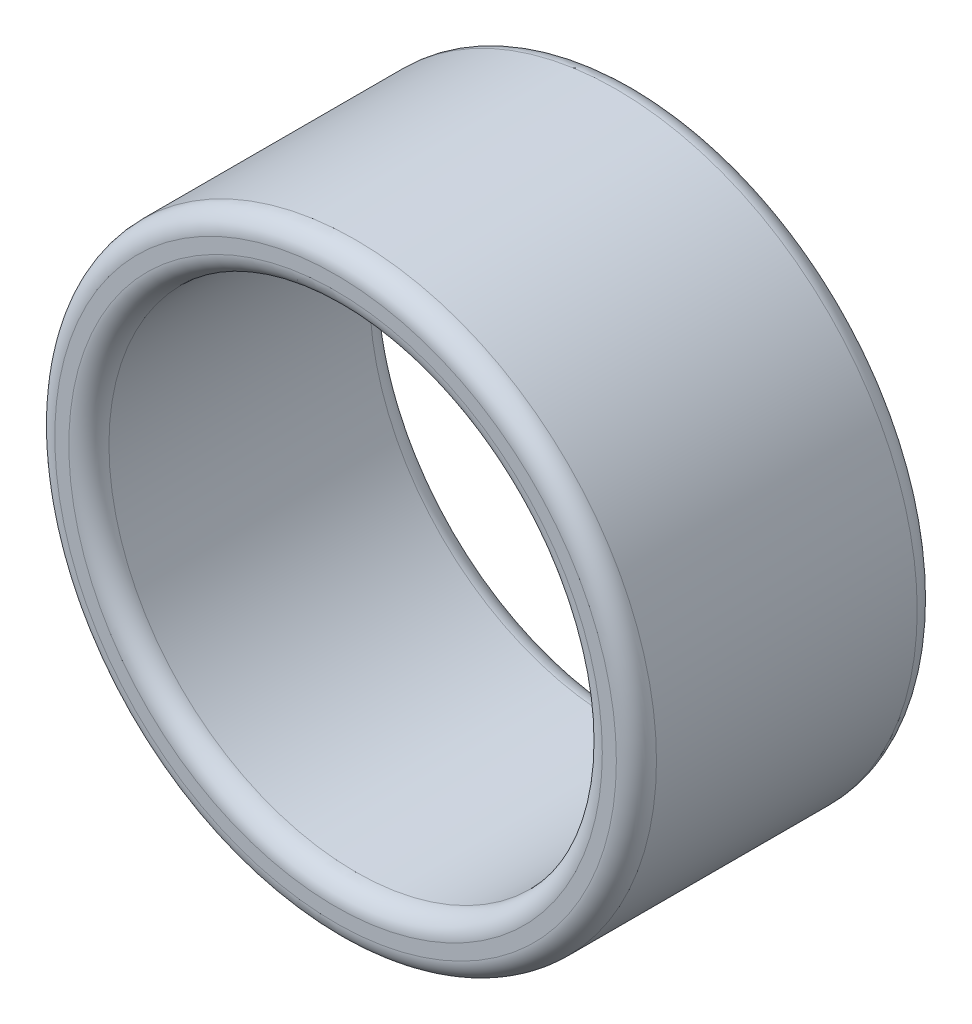
from build123d import *

# Parameters (mm, degrees)
SKETCH1_R           = 1.905
SKETCH1_R_2         = 1.5621
BOSS_EXTRUDE1_DEPTH = 1.905
FILLET1_R           = 0.127


with BuildPart() as part:
    # Sketch1 → Boss-Extrude1 (new body)
    with BuildSketch(Plane.XY):
        Circle(SKETCH1_R)
        Circle(SKETCH1_R_2, mode=Mode.SUBTRACT)
    extrude(amount=BOSS_EXTRUDE1_DEPTH)

    # Fillet1
    fillet1_edges = [part.edges().sort_by_distance(p)[0] for p in [
        (-1.905, 0, 0),
        (-1.905, 0, 1.905),
        (-1.5621, 0, 0),
        (-1.5621, 0, 1.905),
    ]]
    fillet(fillet1_edges, radius=FILLET1_R)


solid = part.part
